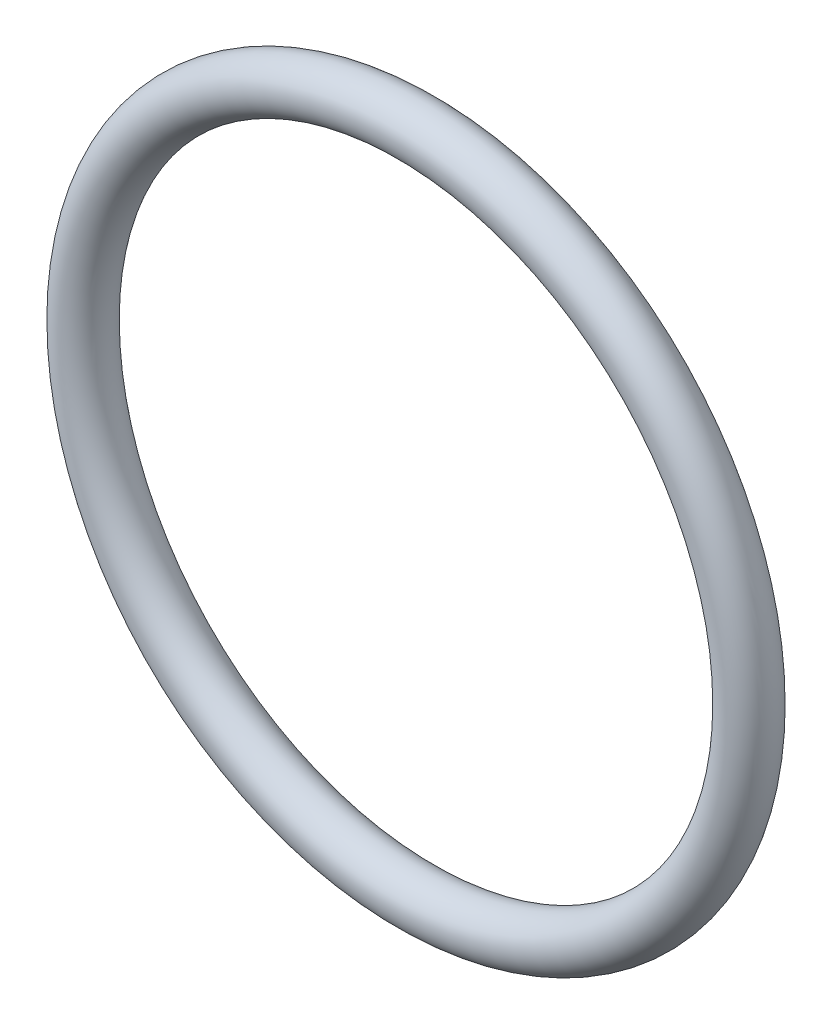
from build123d import *

# Parameters (mm, degrees)
SKETCH2_R = 1.25


with BuildPart() as part:
    # Sweep1: sweep along a path in Sketch1
    with BuildLine(Plane.XY) as sweep1_path:
        CenterArc((0, 0), 15, 0, 360)
    # Sketch2 → Sweep1 (sweep)
    with BuildSketch(Plane(origin=(0, 0, 0), x_dir=(1, 0, 0), z_dir=(0, 1, 0))):
        with Locations((-16.25, 0)):
            Circle(SKETCH2_R)
    sweep(path=sweep1_path.line)


solid = part.part
